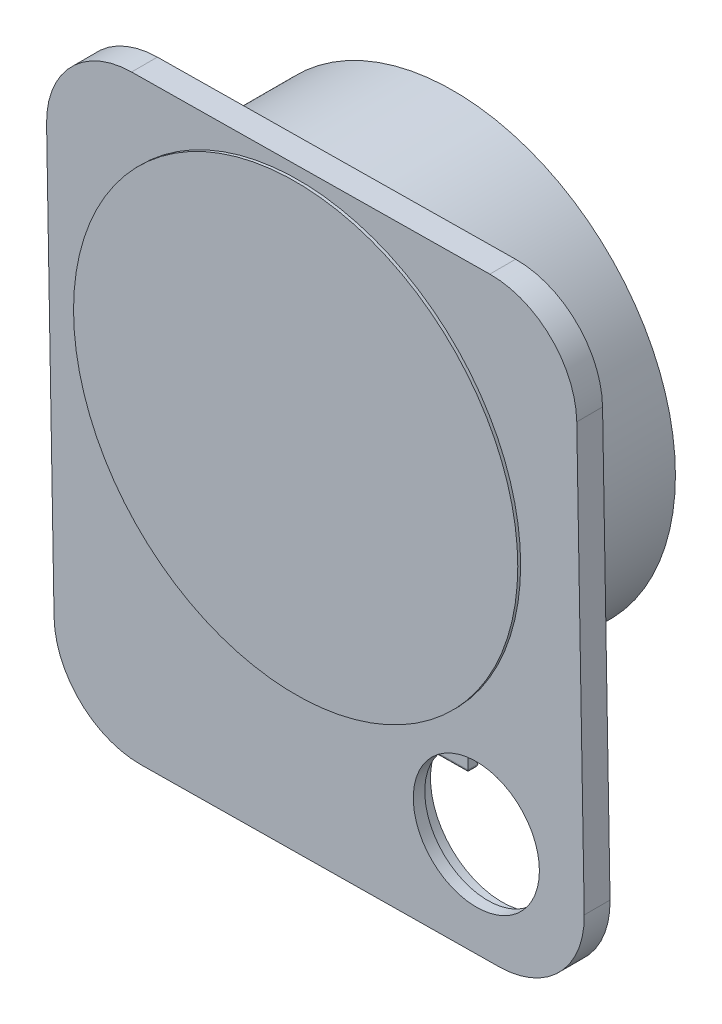
from build123d import *

# Parameters (mm, degrees)
SKETCH1_R                 = 77.5
SKETCH1_R_2               = 22
BOSS_EXTRUDE1_DEPTH       = 4
BOSS_EXTRUDE2_START       = -5
SKETCH1_4_R               = 25
BOSS_EXTRUDE2_DEPTH       = 5
BOSS_EXTRUDE5_START       = -50
SKETCH1_7_R               = 77.5
BOSS_EXTRUDE5_DEPTH       = 50
BOSS_EXTRUDE11_DEPTH      = 35
BOSS_EXTRUDE11_DEPTH_BACK = 35
FILLET6_R                 = 1
SKETCH1_8_R               = 77.5
BOSS_EXTRUDE12_DEPTH      = 5
SKETCH9_W                 = 28.884835104
SKETCH9_H                 = 19.109753223
BOSS_EXTRUDE15_DEPTH      = 5
SKETCH10_W                = 6.135894163
SKETCH10_H                = 2.546187374
SKETCH10_W_2              = 6.094153386
CUT_EXTRUDE1_DEPTH        = 19.109753223
SKETCH9_9_W               = 4.209300424
SKETCH9_9_H               = 19.109753223
BOSS_EXTRUDE16_DEPTH      = 10


with BuildPart() as part:
    # Sketch1 → Boss-Extrude1 (new body)
    with BuildSketch(Plane(origin=(-55.630480005, 66.15900607, 0), x_dir=(0.499999999999998, 0.8660254037844398, 0), z_dir=(0, 0, 1))):
        with BuildLine():
            Line((-189.316298544, 16.630324375), (-62.719050458, 92.734061587))
            ThreePointArc((-62.719050458, 92.734061587), (-39.919544136, 96.109788868), (-21.454102902, 82.317018907))
            Line((-21.454102902, 82.317018907), (42.273246416, -25.216830667))
            ThreePointArc((42.273246416, -25.216830667), (45.552356682, -47.854466687), (31.921457021, -66.223290906))
            Line((31.921457021, -66.223290906), (-94.675791065, -142.327028118))
            ThreePointArc((-94.675791065, -142.327028118), (-117.475297387, -145.7027554), (-135.940738621, -131.909985438))
            Line((-135.940738621, -131.909985438), (-199.668087939, -24.376135865))
            ThreePointArc((-199.668087939, -24.376135865), (-202.947198205, -1.738499844), (-189.316298544, 16.630324375))
        make_face()
        with Locations(Location((-62.487009575, -8.6321901, 0), (0, 0, 300))):
            Circle(SKETCH1_R, mode=Mode.SUBTRACT)
        with Locations(Location((-108.711062401, -106.957491085, 0), (0, 0, 300))):
            Circle(SKETCH1_R_2, mode=Mode.SUBTRACT)
    extrude(amount=BOSS_EXTRUDE1_DEPTH)

    # Sketch1_4 → Boss-Extrude2 (add)
    with BuildSketch(Plane(origin=(-55.630480005, 66.15900607, 0), x_dir=(0.499999999999998, 0.8660254037844398, 0), z_dir=(0, 0, 1)).offset(BOSS_EXTRUDE2_START)):
        with BuildLine():
            Line((-189.316298544, 16.630324375), (-62.719050458, 92.734061587))
            ThreePointArc((-62.719050458, 92.734061587), (-39.919544136, 96.109788868), (-21.454102902, 82.317018907))
            Line((-21.454102902, 82.317018907), (42.273246416, -25.216830667))
            ThreePointArc((42.273246416, -25.216830667), (45.552356682, -47.854466687), (31.921457021, -66.223290906))
            Line((31.921457021, -66.223290906), (-94.675791065, -142.327028118))
            ThreePointArc((-94.675791065, -142.327028118), (-117.475297387, -145.7027554), (-135.940738621, -131.909985438))
            Line((-135.940738621, -131.909985438), (-199.668087939, -24.376135865))
            ThreePointArc((-199.668087939, -24.376135865), (-202.947198205, -1.738499844), (-189.316298544, 16.630324375))
        make_face()
        with Locations(Location((-108.711062401, -106.957491085, 0), (0, 0, 300))):
            Circle(SKETCH1_4_R, mode=Mode.SUBTRACT)
    extrude(amount=BOSS_EXTRUDE2_DEPTH)

    # Sketch1_7 → Boss-Extrude5 (add)
    with BuildSketch(Plane(origin=(-55.630480005, 66.15900607, 0), x_dir=(0.499999999999998, 0.8660254037844398, 0), z_dir=(0, 0, 1)).offset(BOSS_EXTRUDE5_START)):
        with Locations(Location((-62.487009575, -8.6321901, 0), (0, 0, 300))):
            Circle(SKETCH1_7_R)
        Polygon((-84.859101961, 59.5935777), (-112.245619562, 43.13021558), (-129.776834206, 16.41467419), (-133.980473825, -15.261705851), (-124.023956041, -45.625028993), (-101.879291307, -68.661466704), (-71.932502062, -79.808369973), (-40.114917188, -76.8579579), (-12.728399587, -60.39459578), (4.802815056, -33.679054391), (9.006454676, -2.002674349), (-0.950063109, 28.360648792), (-23.094727842, 51.397086504), (-53.041517088, 62.543989773), align=None, mode=Mode.SUBTRACT)
    extrude(amount=BOSS_EXTRUDE5_DEPTH)

    # Sketch8 → Boss-Extrude11 (add, two sides: drawn at the far end of the back side and taken through both)
    with BuildSketch(Plane(origin=(-78.84892316, -0.897416974, 0), x_dir=(0, 0, 1), z_dir=(0.9999352373159692, 0.01138073696455021, 0)).offset(-BOSS_EXTRUDE11_DEPTH_BACK)):
        Polygon((-23.295016777, 86.56703586), (-18.615876211, 86.56703586), (-18.615875095, 65.56703586), (-41.615875095, 65.56703586), (-41.615876211, 86.56703586), (-36.936735645, 86.56703586), (-39.315876073, 83.96703586), (-39.315875265, 68.76703586), (-20.915875265, 68.76703586), (-20.915876073, 83.96703586), align=None)
    extrude(amount=BOSS_EXTRUDE11_DEPTH + BOSS_EXTRUDE11_DEPTH_BACK)

    # Fillet6
    fillet6_edges = [part.edges().sort_by_distance(p)[0] for p in [
        (-77.863726496, -87.45884652, -23.295016777),
        (-42.86599319, -87.060520726, -20.955446494),
        (-77.863726496, -87.45884652, -18.615876211),
        (-77.863726496, -87.45884652, -41.615876211),
        (-42.86599319, -87.060520726, -39.276305928),
        (-77.863726496, -87.45884652, -36.936735645),
        (-77.893316412, -84.859014903, -39.315876073),
        (-77.893316412, -84.859014903, -20.915876073),
        (-112.861459802, -87.857172313, -20.955446494),
        (-112.861459802, -87.857172313, -39.276305928),
    ]]
    fillet(fillet6_edges, radius=FILLET6_R)

    # Sketch1_8 → Boss-Extrude12 (add)
    # profile 1 of 2: a face of its own
    with BuildSketch(Plane(origin=(-55.630480005, 66.15900607, 0), x_dir=(0.499999999999998, 0.8660254037844398, 0), z_dir=(0, 0, 1))):
        with Locations(Location((-62.487009575, -8.6321901, 0), (0, 0, 300))):
            Circle(SKETCH1_8_R)
        Polygon((-53.041517088, 62.543989773), (-84.859101961, 59.5935777), (-112.245619562, 43.13021558), (-129.776834206, 16.41467419), (-133.980473825, -15.261705851), (-124.023956041, -45.625028993), (-101.879291307, -68.661466704), (-71.932502062, -79.808369973), (-40.114917188, -76.8579579), (-12.728399587, -60.39459578), (4.802815056, -33.679054391), (9.006454676, -2.002674349), (-0.950063109, 28.360648792), (-23.094727842, 51.397086504), align=None, mode=Mode.SUBTRACT)
    # profile 2 of 2: a face of its own
    with BuildSketch(Plane(origin=(-55.630480005, 66.15900607, 0), x_dir=(0.499999999999998, 0.8660254037844398, 0), z_dir=(0, 0, 1))):
        Polygon((-23.094727842, 51.397086504), (-53.041517088, 62.543989773), (-84.859101961, 59.5935777), (-112.245619562, 43.13021558), (-129.776834206, 16.41467419), (-133.980473825, -15.261705851), (-124.023956041, -45.625028993), (-101.879291307, -68.661466704), (-71.932502062, -79.808369973), (-40.114917188, -76.8579579), (-12.728399587, -60.39459578), (4.802815056, -33.679054391), (9.006454676, -2.002674349), (-0.950063109, 28.360648792), align=None)
    extrude(amount=BOSS_EXTRUDE12_DEPTH)

    # Sketch9 → Boss-Extrude15 (add)
    with BuildSketch(Plane(origin=(0, 0, -5), x_dir=(-1, 0, 0), z_dir=(0, 0, -1))):
        with Locations((147.381235027, -73.319519351)):
            Rectangle(SKETCH9_W, SKETCH9_H)
    extrude(amount=BOSS_EXTRUDE15_DEPTH)

    # Sketch10 → Cut-Extrude1 (cut)
    with BuildSketch(Plane.XZ.offset(82.874395962)):
        with Locations((-141.22663524, -7.28335185)):
            Rectangle(SKETCH10_W, SKETCH10_H)
        with Locations((-154.687790802, -7.28335185)):
            Rectangle(SKETCH10_W_2, SKETCH10_H)
    extrude(amount=-CUT_EXTRUDE1_DEPTH, mode=Mode.SUBTRACT)

    # Sketch9_9 → Boss-Extrude16 (add)
    with BuildSketch(Plane(origin=(0, 0, -5), x_dir=(-1, 0, 0), z_dir=(0, 0, -1))):
        with Locations((130.834167263, -73.319519351)):
            Rectangle(SKETCH9_9_W, SKETCH9_9_H)
    extrude(amount=BOSS_EXTRUDE16_DEPTH)


solid = part.part
